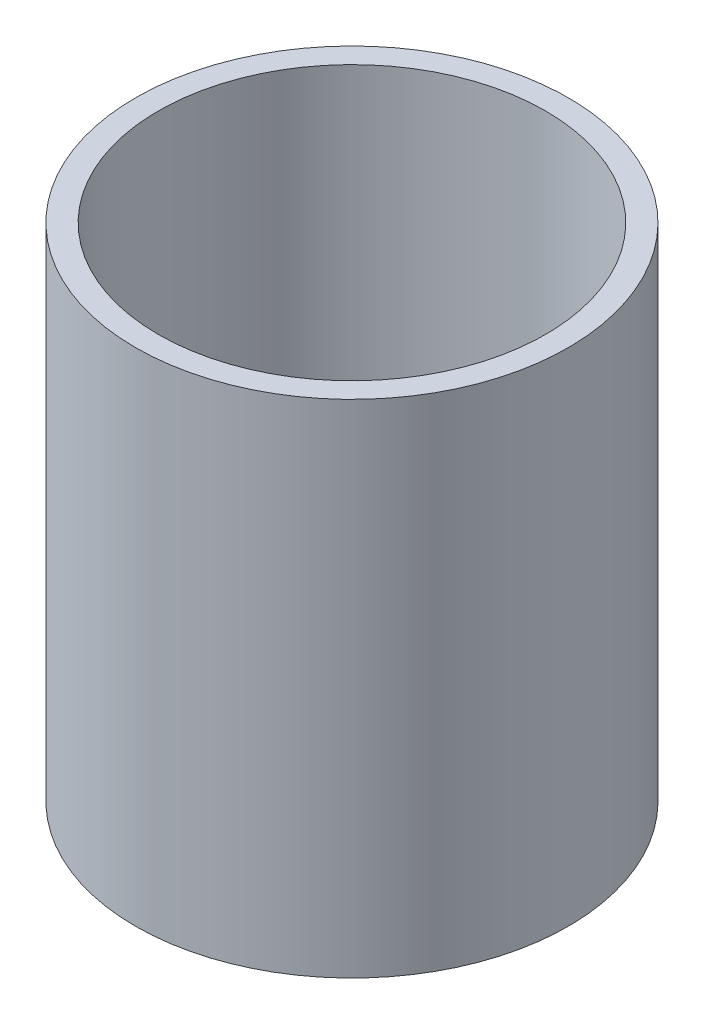
from build123d import *

# Parameters (mm, degrees)
SKETCH1_R           = 19
SKETCH1_R_2         = 17
BOSS_EXTRUDE1_DEPTH = 44


with BuildPart() as part:
    # Sketch1 → Boss-Extrude1 (new body)
    with BuildSketch(Plane(origin=(0, 0, 0), x_dir=(1, 0, 0), z_dir=(0, 1, 0))):
        Circle(SKETCH1_R)
        Circle(SKETCH1_R_2, mode=Mode.SUBTRACT)
    extrude(amount=BOSS_EXTRUDE1_DEPTH)


solid = part.part
